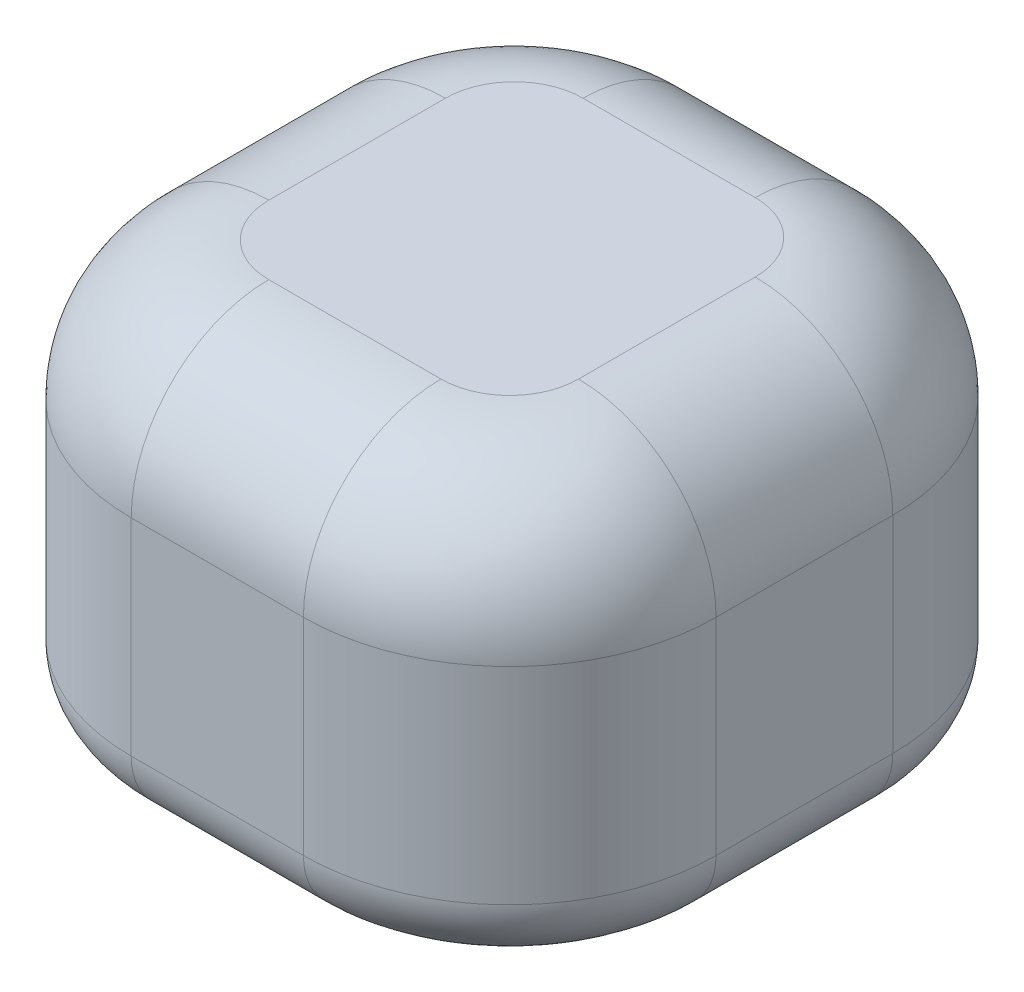
from build123d import *

# Parameters (mm, degrees)
SKETCH1_W                = 85.03995341
SKETCH1_H                = 85.695176246
BOSS_EXTRUDE1_DEPTH      = 30
BOSS_EXTRUDE1_DEPTH_BACK = 30
FILLET1_R                = 30
FILLET2_R                = 20
FILLET3_R                = 10


with BuildPart() as part:
    # Sketch1 → Boss-Extrude1 (new body, two sides)
    with BuildSketch(Plane(origin=(0, 0, 0), x_dir=(1, 0, 0), z_dir=(0, 1, 0))) as boss_extrude1_sk:
        Rectangle(SKETCH1_W, SKETCH1_H)
    extrude(amount=BOSS_EXTRUDE1_DEPTH)
    extrude(boss_extrude1_sk.sketch, amount=-BOSS_EXTRUDE1_DEPTH_BACK)

    # Fillet1
    fillet1_edges = [part.edges().sort_by_distance(p)[0] for p in [
        (42.519976705, 0, 42.847588123),
        (-42.519976705, 0, 42.847588123),
        (-42.519976705, 0, -42.847588123),
        (42.519976705, 0, -42.847588123),
    ]]
    fillet(fillet1_edges, radius=FILLET1_R)

    # Fillet2
    fillet2_edges = [part.edges().sort_by_distance(p)[0] for p in [
        (0, 30, 42.847588123),
        (42.519976705, 30, 0),
        (0, 30, -42.847588123),
        (-42.519976705, 30, 0),
        (-33.73318014, 30, -34.060791558),
        (-33.73318014, 30, 34.060791558),
        (33.73318014, 30, -34.060791558),
        (33.73318014, 30, 34.060791558),
    ]]
    fillet(fillet2_edges, radius=FILLET2_R)

    # Fillet3
    fillet3_edges = [part.edges().sort_by_distance(p)[0] for p in [
        (0, -30, 42.847588123),
        (42.519976705, -30, 0),
        (-42.519976705, -30, 0),
        (0, -30, -42.847588123),
        (-33.73318014, -30, -34.060791558),
        (-33.73318014, -30, 34.060791558),
        (33.73318014, -30, -34.060791558),
        (33.73318014, -30, 34.060791558),
    ]]
    fillet(fillet3_edges, radius=FILLET3_R)


solid = part.part
